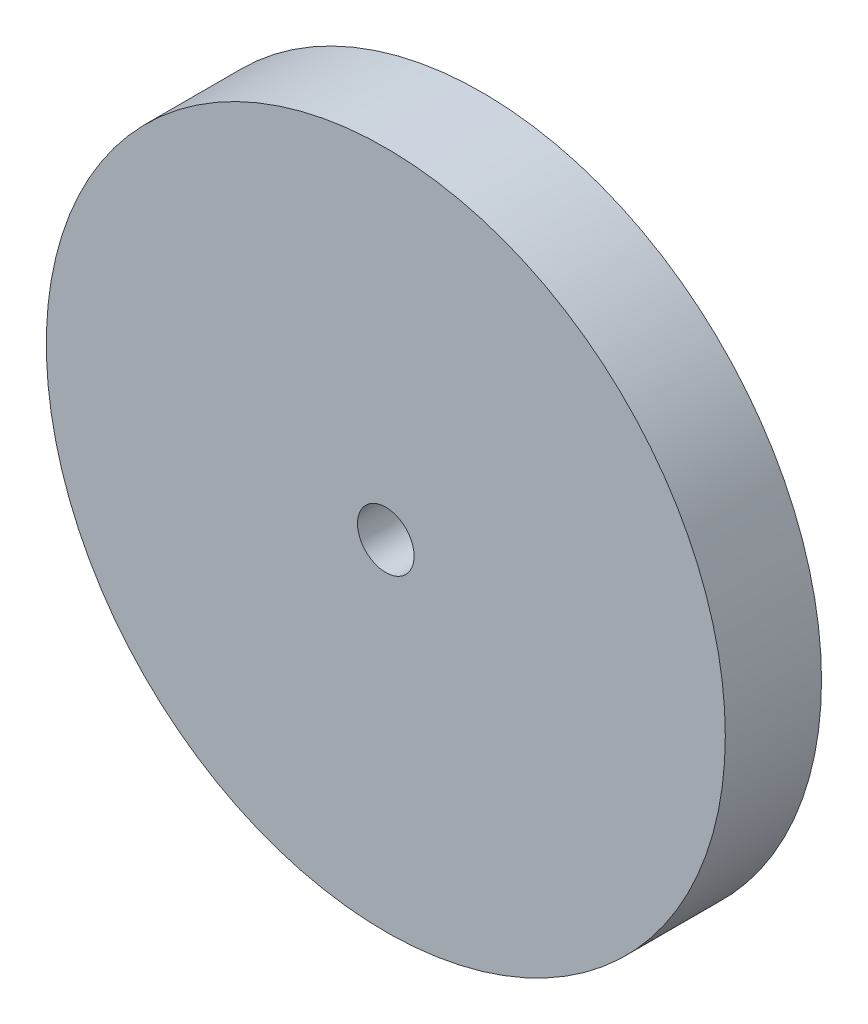
from build123d import *

# Parameters (mm, degrees)
SKETCH1_R           = 30
BOSS_EXTRUDE1_DEPTH = 8.5
SKETCH2_R           = 6
SKETCH2_R_2         = 2.5
BOSS_EXTRUDE2_DEPTH = 10
SKETCH3_R           = 2.5
CUT_EXTRUDE1_DEPTH  = 19.5


with BuildPart() as part:
    # Sketch1 → Boss-Extrude1 (new body)
    with BuildSketch(Plane.XY):
        Circle(SKETCH1_R)
    extrude(amount=BOSS_EXTRUDE1_DEPTH)

    # Sketch2 → Boss-Extrude2 (add)
    with BuildSketch(Plane(origin=(0, 0, 0), x_dir=(-1, 0, 0), z_dir=(0, 0, -1))):
        Circle(SKETCH2_R)
        Circle(SKETCH2_R_2, mode=Mode.SUBTRACT)
    extrude(amount=BOSS_EXTRUDE2_DEPTH)

    # Sketch3 → Cut-Extrude1 (cut, through all)
    with BuildSketch(Plane(origin=(0, 0, -10), x_dir=(-1, 0, 0), z_dir=(0, 0, -1))):
        Circle(SKETCH3_R)
    extrude(amount=-CUT_EXTRUDE1_DEPTH, mode=Mode.SUBTRACT)


solid = part.part
